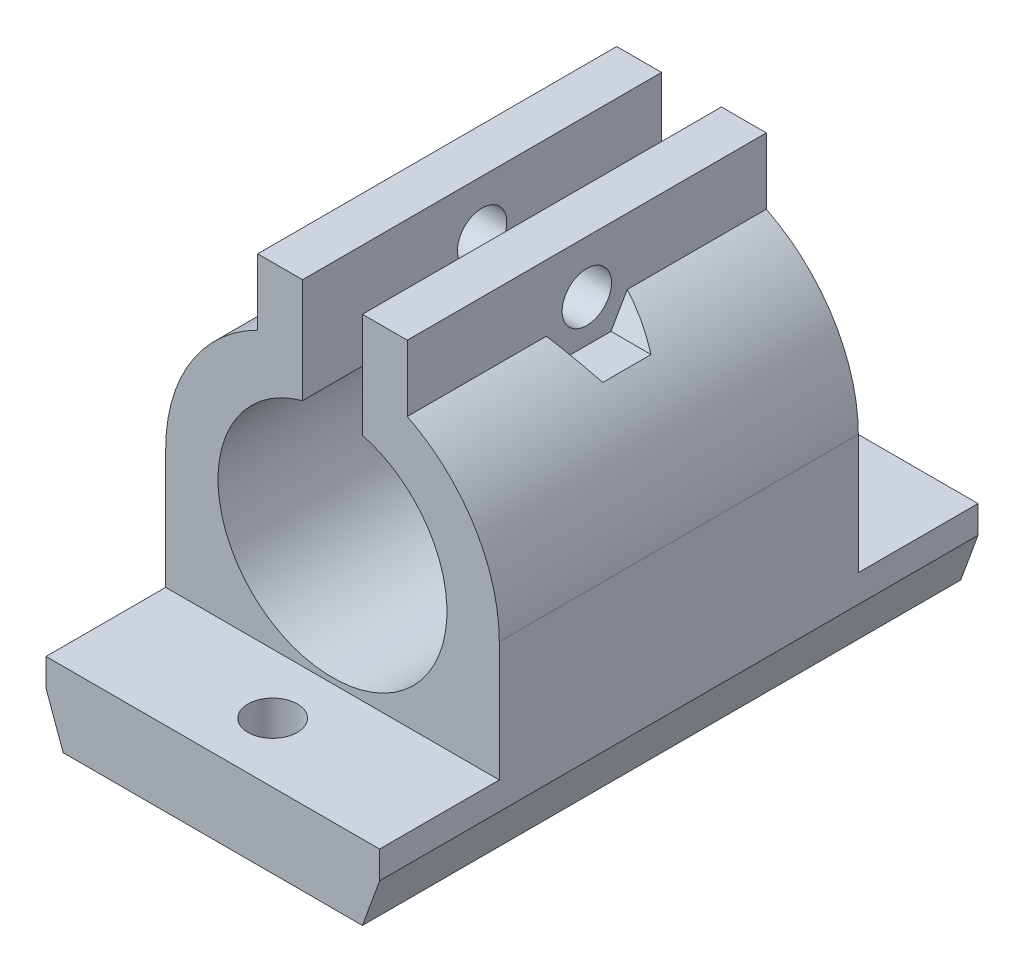
from build123d import *

# Parameters (mm, degrees)
RESSALTO_EXTRUS_O1_DEPTH   = 40
ESBO_O2_W                  = 22.3
ESBO_O2_H                  = 8
CORTE_EXTRUS_O1_DEPTH      = 22.383935
ESBO_O3_R                  = 1.65
CORTE_EXTRUS_O2_DEPTH      = 5
ESBO_O4_R                  = 1.65
CORTE_EXTRUS_O3_DEPTH      = 7.15
CORTE_EXTRUS_O3_DEPTH_BACK = 17.15
ESBO_O5_R                  = 3.5
CORTE_EXTRUS_O4_DEPTH      = 10
CORTE_EXTRUS_O5_DEPTH      = 10
CHANFRO1_SIZE              = 1.15
CHANFRO1_SIZE2             = 3.159599032


with BuildPart() as part:
    # Esboço1 → Ressalto-extrusão1 (new body)
    with BuildSketch(Plane.XY):
        with BuildLine():
            Line((5, 14.383935265), (5, 9.966067429))
            ThreePointArc((5, 9.966067429), (9.488743331, 5.855446183), (11.15, 0))
            Line((11.15, 0), (11.15, -13))
            Line((11.15, -13), (-11.15, -13))
            Line((-11.15, -13), (-11.15, 0))
            ThreePointArc((-11.15, 0), (-9.488743331, 5.855446183), (-5, 9.966067429))
            Line((-5, 9.966067429), (-5, 14.383935265))
            Line((-5, 14.383935265), (-2, 14.383935265))
            Line((-2, 14.383935265), (-2, 7.383935265))
            ThreePointArc((-2, 7.383935265), (0, -7.65), (2, 7.383935265))
            Line((2, 7.383935265), (2, 14.383935265))
            Line((2, 14.383935265), (5, 14.383935265))
        make_face()
    extrude(amount=RESSALTO_EXTRUS_O1_DEPTH)

    # Esboço2 → Corte-extrusão1 (cut)
    with BuildSketch(Plane(origin=(0, 14.383935265, 0), x_dir=(1, 0, 0), z_dir=(0, 1, 0))):
        with Locations((0, -36)):
            Rectangle(ESBO_O2_W, ESBO_O2_H)
        with Locations((0, -4)):
            Rectangle(ESBO_O2_W, ESBO_O2_H)
    extrude(amount=-CORTE_EXTRUS_O1_DEPTH, mode=Mode.SUBTRACT)

    # Esboço3 → Corte-extrusão2 (cut)
    with BuildSketch(Plane(origin=(0, -8, 0), x_dir=(1, 0, 0), z_dir=(0, 1, 0))):
        with Locations((0, -4)):
            Circle(ESBO_O3_R)
        with Locations((0, -36)):
            Circle(ESBO_O3_R)
    extrude(amount=-CORTE_EXTRUS_O2_DEPTH, mode=Mode.SUBTRACT)

    # Esboço4 → Corte-extrusão3 (cut, two sides)
    with BuildSketch(Plane.ZY.offset(5)) as corte_extrus_o3_sk:
        with Locations((20, 10.883935265)):
            Circle(ESBO_O4_R)
    extrude(amount=CORTE_EXTRUS_O3_DEPTH, mode=Mode.SUBTRACT)
    extrude(corte_extrus_o3_sk.sketch, amount=-CORTE_EXTRUS_O3_DEPTH_BACK, mode=Mode.SUBTRACT)

    # Esboço5 → Corte-extrusão4 (cut)
    with BuildSketch(Plane.ZY.offset(5)):
        with Locations((20, 10.883935265)):
            Circle(ESBO_O5_R)
    extrude(amount=CORTE_EXTRUS_O4_DEPTH, mode=Mode.SUBTRACT)

    # Esboço6 → Corte-extrusão5 (cut)
    with BuildSketch(Plane(origin=(5, 0, 0), x_dir=(0, 0, -1), z_dir=(1, 0, 0))):
        Polygon((-16.766838493, 10.883935265), (-18.383419246, 13.683935265), (-21.616580754, 13.683935265), (-23.233161507, 10.883935265), (-21.616580754, 8.083935265), (-18.383419246, 8.083935265), align=None)
    extrude(amount=CORTE_EXTRUS_O5_DEPTH, mode=Mode.SUBTRACT)

    # Chanfro1
    chanfro1_edges = [part.edges().sort_by_distance(p)[0] for p in [
        (11.15, -13, 20),
        (-11.15, -13, 20),
    ]]
    chanfro1_side = [part.faces().sort_by_distance(p)[0] for p in [
        (0, -13, 20),
    ]]
    chamfer(chanfro1_edges, length=CHANFRO1_SIZE, length2=CHANFRO1_SIZE2, reference=chanfro1_side[0])


solid = part.part
